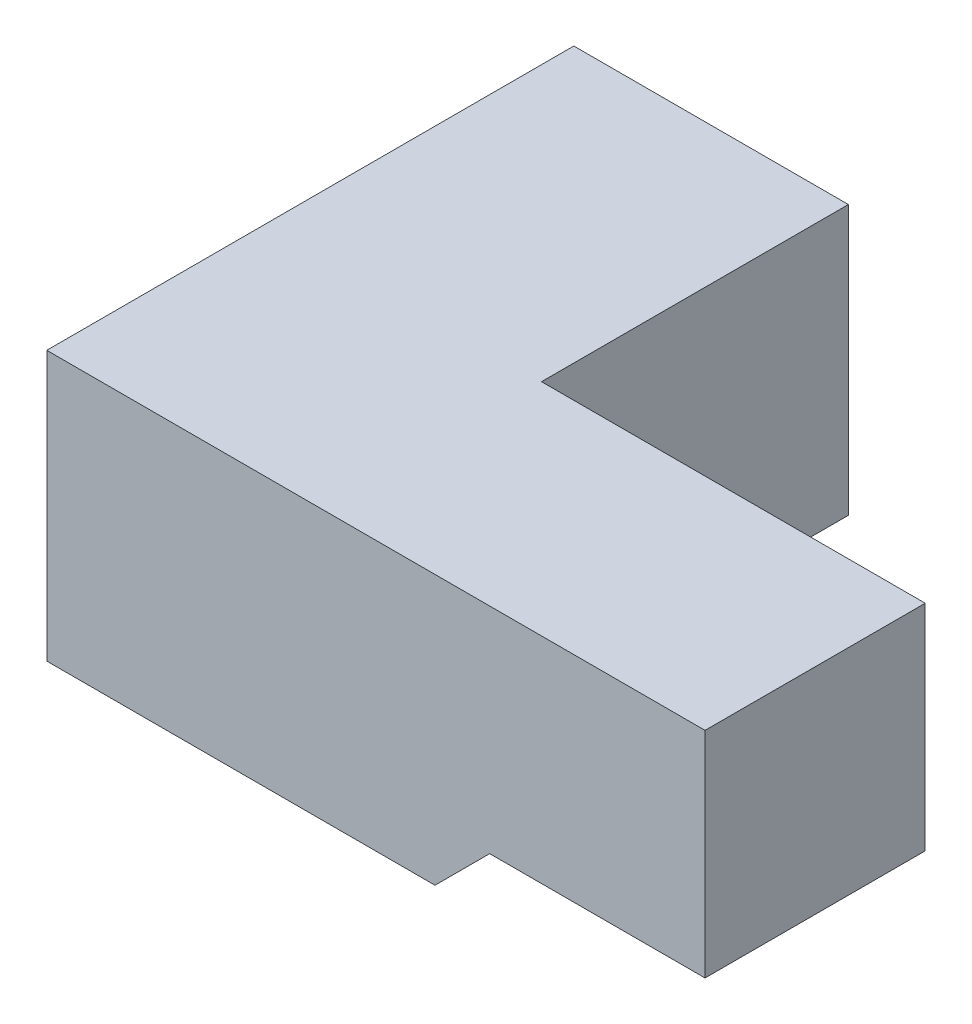
from build123d import *

# Parameters (mm, degrees)
SKIZZE7_W                       = 510
SKIZZE7_H                       = 500
AUFSATZ_LINEAR_AUSTRAGEN1_DEPTH = 979
SKIZZE8_W                       = 409
SKIZZE8_H                       = 398.4
AUFSATZ_LINEAR_AUSTRAGEN2_DEPTH = 1222.75
SKIZZE9_W                       = 409
SKIZZE9_H                       = 500
AUFSATZ_LINEAR_AUSTRAGEN3_DEPTH = 721.15
FORMSCHR_GE1_ANGLE              = 45


with BuildPart() as part:
    # Skizze7 → Aufsatz-Linear austragen1 (new body)
    with BuildSketch(Plane.XY):
        Rectangle(SKIZZE7_W, SKIZZE7_H)
    extrude(amount=AUFSATZ_LINEAR_AUSTRAGEN1_DEPTH)

    # Skizze8 → Aufsatz-Linear austragen2 (add)
    with BuildSketch(Plane.ZY.offset(255)):
        with Locations((774.5, 50.8)):
            Rectangle(SKIZZE8_W, SKIZZE8_H)
    extrude(amount=-AUFSATZ_LINEAR_AUSTRAGEN2_DEPTH)

    # Skizze9 → Aufsatz-Linear austragen3 (add)
    with BuildSketch(Plane.ZY.offset(255)):
        with Locations((774.5, 0)):
            Rectangle(SKIZZE9_W, SKIZZE9_H)
    extrude(amount=-AUFSATZ_LINEAR_AUSTRAGEN3_DEPTH)

    # Formschräge1
    formschr_ge1_faces = [part.faces().sort_by_distance(p)[0] for p in [
        (466.15, -199.2, 774.5),
    ]]
    draft(formschr_ge1_faces, Plane(origin=(-255, -250, 979), x_dir=(0, 0, -1), z_dir=(0, -1, 0)), FORMSCHR_GE1_ANGLE)


solid = part.part
